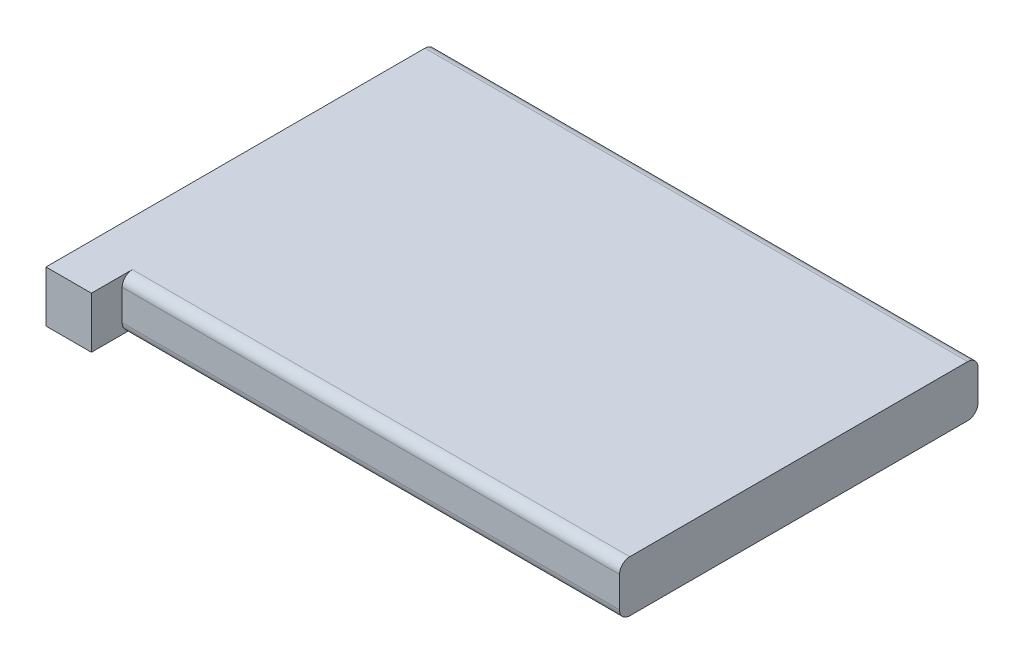
from build123d import *

# Parameters (mm, degrees)
SKETCH1_W                = 53
SKETCH1_H                = 35
BOSS_EXTRUDE1_DEPTH      = 5
FILLET1_R                = 1
SKETCH2_W                = 4.435881082
SKETCH2_H                = 5
BOSS_EXTRUDE2_DEPTH      = 3
BOSS_EXTRUDE2_DEPTH_BACK = 4.5


with BuildPart() as part:
    # Sketch1 → Boss-Extrude1 (new body)
    with BuildSketch(Plane(origin=(0, 0, 0), x_dir=(1, 0, 0), z_dir=(0, 1, 0))):
        Rectangle(SKETCH1_W, SKETCH1_H)
    extrude(amount=BOSS_EXTRUDE1_DEPTH)

    # Fillet1
    fillet1_edges = [part.edges().sort_by_distance(p)[0] for p in [
        (0, 0, 17.5),
        (0, 5, 17.5),
        (0, 0, -17.5),
        (0, 5, -17.5),
    ]]
    fillet(fillet1_edges, radius=FILLET1_R)

    # Sketch2 → Boss-Extrude2 (add, two sides)
    with BuildSketch(Plane.XY.offset(17.5)) as boss_extrude2_sk:
        with Locations((-24.282059459, 2.5)):
            Rectangle(SKETCH2_W, SKETCH2_H)
    extrude(amount=BOSS_EXTRUDE2_DEPTH)
    extrude(boss_extrude2_sk.sketch, amount=-BOSS_EXTRUDE2_DEPTH_BACK)


solid = part.part
